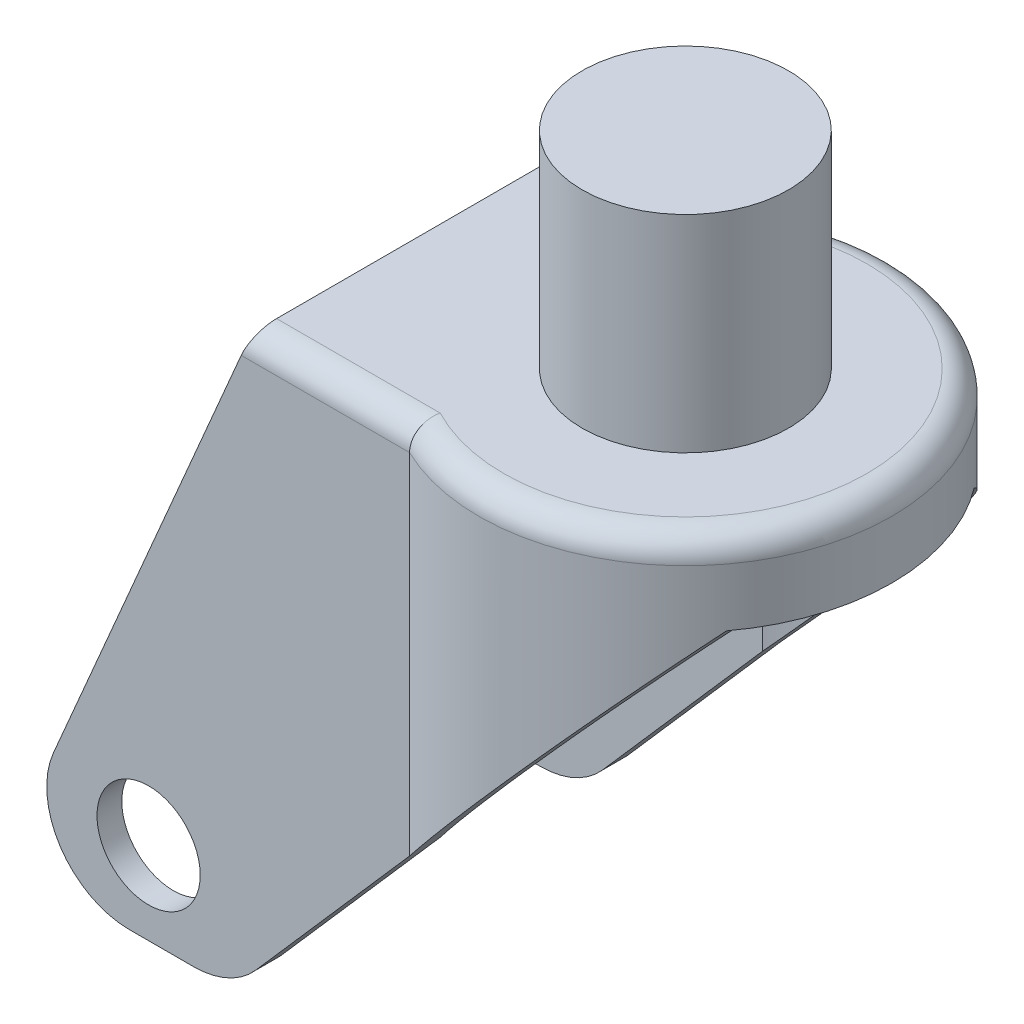
from build123d import *

# Parameters (mm, degrees)
SKETCH2_R               = 25
SKETCH2_R_2             = 22
EXTRUDE_THIN1_DEPTH     = 60
SKETCH3_W               = 45
SKETCH3_H               = 70
SKETCH3_W_2             = 39
SKETCH3_H_2             = 64
EXTRUDE_THIN2_DEPTH     = 60
SKETCH4_R               = 22
CUT_EXTRUDE1_DEPTH      = 71
CUT_EXTRUDE2_DEPTH      = 26
CUT_EXTRUDE2_DEPTH_BACK = 26
SKETCH6_W               = 39
SKETCH6_H               = 64
CUT_EXTRUDE3_DEPTH      = 50
CUT_EXTRUDE4_DEPTH      = 26
CUT_EXTRUDE4_DEPTH_BACK = 26
SKETCH8_W               = 35
SKETCH8_H               = 39
CUT_EXTRUDE6_DEPTH      = 4
BOSS_EXTRUDE1_DEPTH     = 3
FILLET1_R               = 3
SKETCH10_R              = 6.25
CUT_EXTRUDE7_DEPTH      = 48.5000001
FILLET3_R               = 10
SKETCH11_R              = 12.5
BOSS_EXTRUDE2_DEPTH     = 25


with BuildPart() as part:
    # Sketch2 → Extrude-Thin1 (new body)
    with BuildSketch(Plane(origin=(0, 0, 0), x_dir=(1, 0, 0), z_dir=(0, 1, 0))):
        Circle(SKETCH2_R)
        Circle(SKETCH2_R_2, mode=Mode.SUBTRACT)
    extrude(amount=-EXTRUDE_THIN1_DEPTH)

    # Sketch3 → Extrude-Thin2 (add)
    with BuildSketch(Plane(origin=(0, 0, 0), x_dir=(0, 0, -1), z_dir=(1, 0, 0))):
        with Locations((0, -35)):
            Rectangle(SKETCH3_W, SKETCH3_H)
        with Locations((0, -35)):
            Rectangle(SKETCH3_W_2, SKETCH3_H_2, mode=Mode.SUBTRACT)
    extrude(amount=-EXTRUDE_THIN2_DEPTH)

    # Sketch4 → Cut-Extrude1 (cut, through all)
    with BuildSketch(Plane(origin=(0, 0, 0), x_dir=(1, 0, 0), z_dir=(0, 1, 0))):
        Circle(SKETCH4_R)
    extrude(amount=-CUT_EXTRUDE1_DEPTH, mode=Mode.SUBTRACT)

    # Sketch5 → Cut-Extrude2 (cut, two sides)
    with BuildSketch(Plane.XY) as cut_extrude2_sk:
        Polygon((20, -10), (-50, -90), (25, -90), (25, -10), align=None)
    extrude(amount=CUT_EXTRUDE2_DEPTH, mode=Mode.SUBTRACT)
    extrude(cut_extrude2_sk.sketch, amount=-CUT_EXTRUDE2_DEPTH_BACK, mode=Mode.SUBTRACT)

    # Sketch6 → Cut-Extrude3 (cut)
    with BuildSketch(Plane.ZY.offset(60)):
        with Locations((0, -35)):
            Rectangle(SKETCH6_W, SKETCH6_H)
    extrude(amount=-CUT_EXTRUDE3_DEPTH, mode=Mode.SUBTRACT)

    # Sketch7 → Cut-Extrude4 (cut, two sides)
    with BuildSketch(Plane.XY) as cut_extrude4_sk:
        Polygon((-30, 0), (-60, -70), (-60, 0), align=None)
    extrude(amount=CUT_EXTRUDE4_DEPTH, mode=Mode.SUBTRACT)
    extrude(cut_extrude4_sk.sketch, amount=-CUT_EXTRUDE4_DEPTH_BACK, mode=Mode.SUBTRACT)

    # Sketch8 → Cut-Extrude6 (cut, through all)
    with BuildSketch(Plane(origin=(0, -67, 0), x_dir=(1, 0, 0), z_dir=(0, 1, 0))):
        with Locations((-47.375, 0)):
            Rectangle(SKETCH8_W, SKETCH8_H)
    extrude(amount=-CUT_EXTRUDE6_DEPTH, mode=Mode.SUBTRACT)

    # Sketch9 → Boss-Extrude1 (add)
    with BuildSketch(Plane(origin=(0, 0, 0), x_dir=(1, 0, 0), z_dir=(0, 1, 0))):
        with BuildLine():
            Line((-30, 22.5), (-10.897247359, 22.5))
            ThreePointArc((-10.897247359, 22.5), (25, 0), (-10.897247359, -22.5))
            Line((-10.897247359, -22.5), (-30, -22.5))
            Line((-30, -22.5), (-30, 22.5))
        make_face()
    extrude(amount=-BOSS_EXTRUDE1_DEPTH)

    # Fillet1
    fillet1_edges = [part.edges().sort_by_distance(p)[0] for p in [
        (25, 0, 0),
        (-20.448623679, 0, -22.5),
        (-20.448623679, 0, 22.5),
    ]]
    fillet(fillet1_edges, radius=FILLET1_R)

    # Sketch10 → Cut-Extrude7 (cut, through all)
    with BuildSketch(Plane.XY.offset(22.5)):
        with Locations((-42.5, -60)):
            Circle(SKETCH10_R)
    extrude(amount=-CUT_EXTRUDE7_DEPTH, mode=Mode.SUBTRACT)

    # Fillet3
    fillet3_edges = [part.edges().sort_by_distance(p)[0] for p in [
        (-60, -70, -21),
        (-32.5, -70, -21),
        (-60, -70, 21),
        (-32.5, -70, 21),
    ]]
    fillet(fillet3_edges, radius=FILLET3_R)

    # Sketch11 → Boss-Extrude2 (add)
    with BuildSketch(Plane(origin=(0, 0, 0), x_dir=(1, 0, 0), z_dir=(0, 1, 0))):
        Circle(SKETCH11_R)
    extrude(amount=BOSS_EXTRUDE2_DEPTH)


solid = part.part
